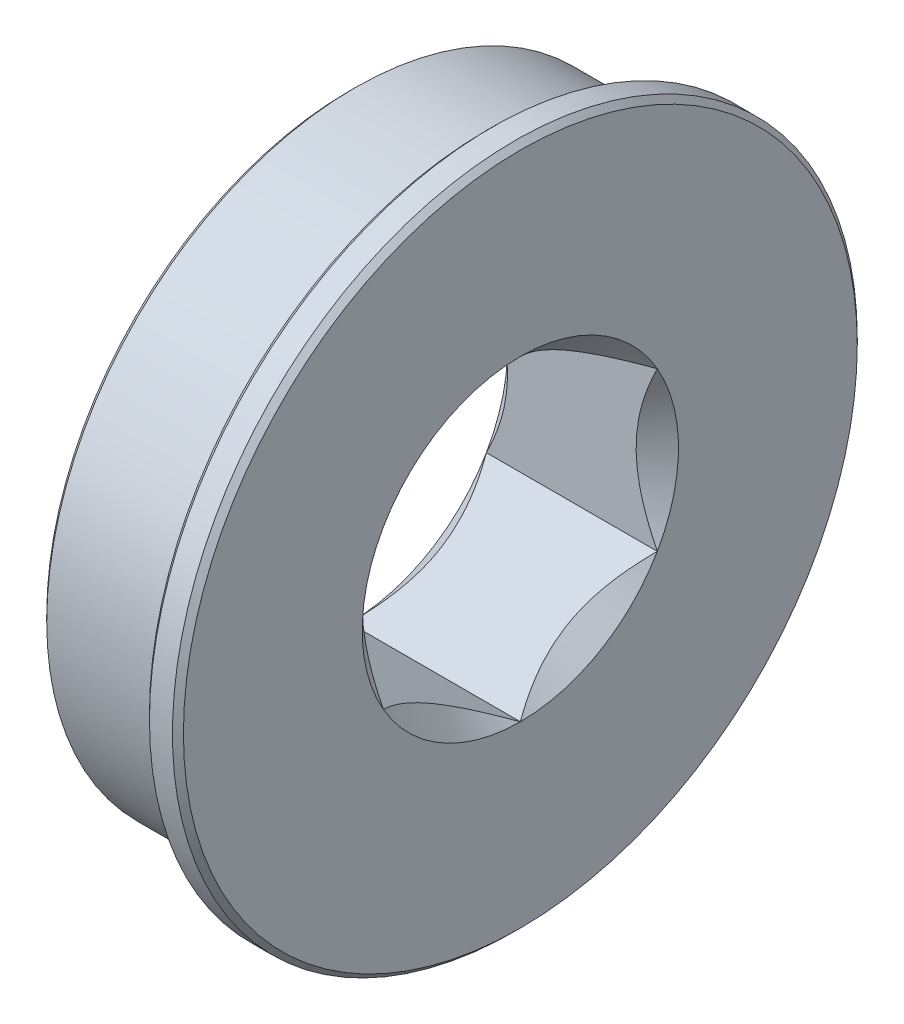
from build123d import *

# Parameters (mm, degrees)
CUT_EXTRUDE1_DEPTH = 8.9248
CHAMFER1_SIZE      = 0.254


with BuildPart() as part:
    # Sketch1 → Revolve1 (revolve)
    with BuildSketch(Plane.XY):
        Polygon((-3.9624, 14.2875), (2.3876, 14.2875), (2.3876, 15.875), (3.9624, 15.875), (3.9624, 7.332348419), (2.980051581, 6.35), (-2.980051581, 6.35), (-3.9624, 7.332348419), align=None)
    revolve(axis=Axis((3.9624, 0, 0), (-1, 0, 0)))

    # Sketch2 → Cut-Extrude1 (cut, through all)
    with BuildSketch(Plane(origin=(3.9624, 0, 0), x_dir=(0, 0, -1), z_dir=(1, 0, 0))):
        Polygon((0, 7.332348419), (-6.35, 3.666174209), (-6.35, -3.666174209), (0, -7.332348419), (6.35, -3.666174209), (6.35, 3.666174209), align=None)
    extrude(amount=-CUT_EXTRUDE1_DEPTH, mode=Mode.SUBTRACT)

    # Chamfer1
    chamfer1_edges = [part.edges().sort_by_distance(p)[0] for p in [
        (3.9624, -15.875, 0),
        (2.3876, -15.875, 0),
        (-3.9624, -14.2875, 0),
    ]]
    chamfer(chamfer1_edges, length=CHAMFER1_SIZE)


solid = part.part
